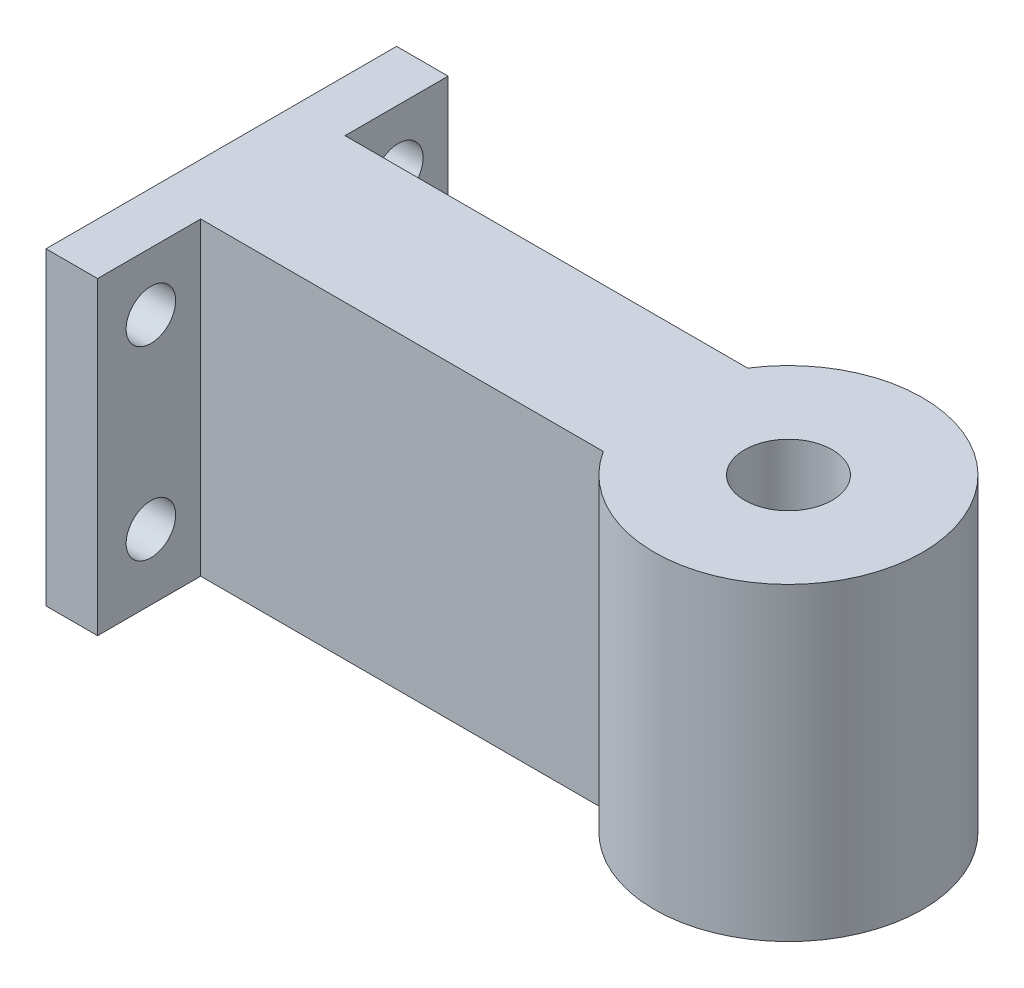
from build123d import *

# Parameters (mm, degrees)
SKETCH2_R           = 4.25
BOSS_EXTRUDE1_DEPTH = 30
SKETCH3_R           = 11.25
SKETCH3_R_2         = 5.25
SKETCH3_R_3         = 4.25
CUT_EXTRUDE1_DEPTH  = 5
CUT_EXTRUDE2_START  = -5
SKETCH3_3_R         = 5.25
SKETCH3_3_R_2       = 4.25
CUT_EXTRUDE2_DEPTH  = 10.6
SKETCH4_R           = 2.4
CUT_EXTRUDE3_DEPTH  = 72.819217484


with BuildPart() as part:
    # Sketch2 → Boss-Extrude1 (new body)
    with BuildSketch(Plane(origin=(0, 0, 0), x_dir=(1, 0, 0), z_dir=(0, 1, 0))):
        with BuildLine():
            Line((0, 17), (0, -17))
            Line((0, -17), (5, -17))
            Line((5, -17), (5, -7))
            Line((5, -7), (44.04554885, -7))
            ThreePointArc((44.04554885, -7), (68, 0), (44.04554885, 7))
            Line((44.04554885, 7), (5, 7))
            Line((5, 7), (5, 17))
            Line((5, 17), (0, 17))
        make_face()
        with Locations(Location((55, 0, 0), (0, 0, 270))):
            Circle(SKETCH2_R, mode=Mode.SUBTRACT)
    extrude(amount=BOSS_EXTRUDE1_DEPTH)

    # Sketch3 → Cut-Extrude1 (cut)
    with BuildSketch(Plane.XZ):
        with Locations(Location((55, 0, 0), (0, 0, 270))):
            Circle(SKETCH3_R)
        with Locations((55, 0)):
            Circle(SKETCH3_R_2, mode=Mode.SUBTRACT)
        with Locations((55, 0)):
            Circle(SKETCH3_R_2)
        with Locations(Location((55, 0, 0), (0, 0, 270))):
            Circle(SKETCH3_R_3, mode=Mode.SUBTRACT)
    extrude(amount=-CUT_EXTRUDE1_DEPTH, mode=Mode.SUBTRACT)

    # Sketch3_3 → Cut-Extrude2 (cut)
    with BuildSketch(Plane.XZ.offset(CUT_EXTRUDE2_START)):
        with Locations(Location((55, 0, 0), (0, 0, 270))):
            Circle(SKETCH3_3_R)
        with Locations(Location((55, 0, 0), (0, 0, 270))):
            Circle(SKETCH3_3_R_2, mode=Mode.SUBTRACT)
    extrude(amount=-CUT_EXTRUDE2_DEPTH, mode=Mode.SUBTRACT)

    # Sketch4 → Cut-Extrude3 (cut, through all)
    with BuildSketch(Plane(origin=(5, 0, 0), x_dir=(0, 0, -1), z_dir=(1, 0, 0))):
        with Locations((12.17186788, 24.363439063)):
            Circle(SKETCH4_R)
        with Locations((12.17186788, 6.363439063)):
            Circle(SKETCH4_R)
        with Locations((-11.82813212, 6.363439063)):
            Circle(SKETCH4_R)
        with Locations((-11.82813212, 24.363439063)):
            Circle(SKETCH4_R)
    extrude(amount=-CUT_EXTRUDE3_DEPTH, mode=Mode.SUBTRACT)


solid = part.part
